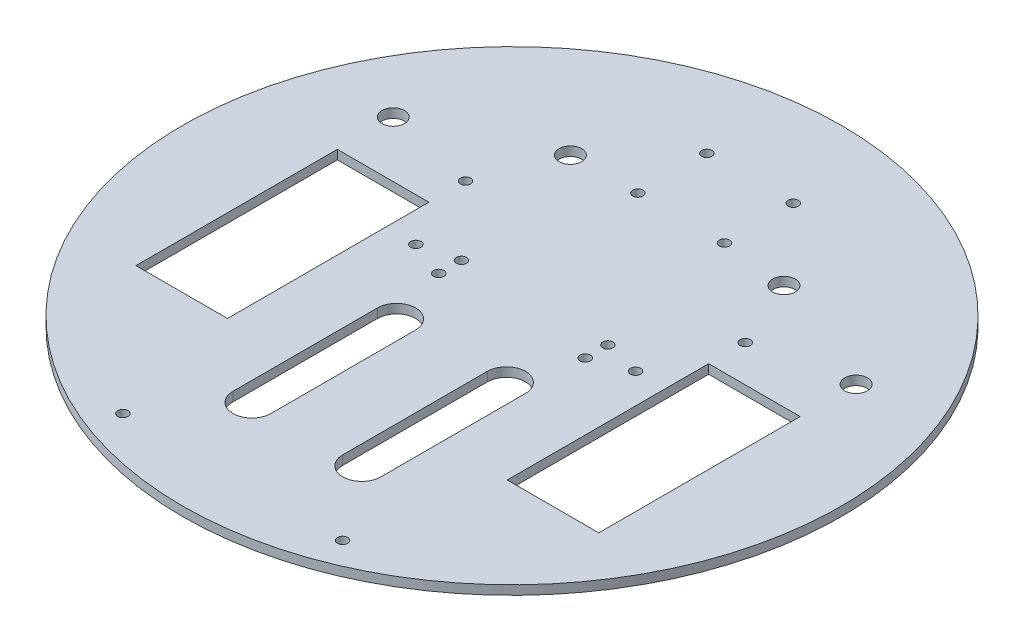
from build123d import *

# Parameters (mm, degrees)
SKETCH1_R           = 114.3
SKETCH1_R_2         = 1.778
SKETCH1_W           = 31.75
SKETCH1_H           = 69.85
BOSS_EXTRUDE1_DEPTH = 3.175
SKETCH2_R           = 1.778
SKETCH2_R_2         = 3.914780109
CUT_EXTRUDE1_DEPTH  = 25.4


with BuildPart() as part:
    # Sketch1 → Boss-Extrude1 (new body)
    with BuildSketch(Plane(origin=(0, 0, 0), x_dir=(1, 0, 0), z_dir=(0, 1, 0))):
        Circle(SKETCH1_R)
        with Locations((-14.986, 82.55)):
            Circle(SKETCH1_R_2, mode=Mode.SUBTRACT)
        with Locations((14.986, 82.55)):
            Circle(SKETCH1_R_2, mode=Mode.SUBTRACT)
        with Locations((-14.986, 58.674)):
            Circle(SKETCH1_R_2, mode=Mode.SUBTRACT)
        with Locations((14.986, 58.674)):
            Circle(SKETCH1_R_2, mode=Mode.SUBTRACT)
        with Locations((25.4, 7.874)):
            Circle(SKETCH1_R_2, mode=Mode.SUBTRACT)
        with Locations((25.4, 0)):
            Circle(SKETCH1_R_2, mode=Mode.SUBTRACT)
        with Locations((-25.4, 7.874)):
            Circle(SKETCH1_R_2, mode=Mode.SUBTRACT)
        with Locations((-25.4, 0)):
            Circle(SKETCH1_R_2, mode=Mode.SUBTRACT)
        with Locations((64.389, -15.24)):
            Rectangle(SKETCH1_W, SKETCH1_H, mode=Mode.SUBTRACT)
        with Locations((-64.389, -15.24)):
            Rectangle(SKETCH1_W, SKETCH1_H, mode=Mode.SUBTRACT)
    extrude(amount=BOSS_EXTRUDE1_DEPTH)

    # Sketch2 → Cut-Extrude1 (cut)
    with BuildSketch(Plane(origin=(0, 3.175, 0), x_dir=(1, 0, 0), z_dir=(0, 1, 0))):
        with Locations((-48.514, 32.385)):
            Circle(SKETCH2_R)
        with Locations((48.514, 32.385)):
            Circle(SKETCH2_R)
        with Locations((38.1, 4.739101121)):
            Circle(SKETCH2_R)
        with Locations((-38.1, 4.739101121)):
            Circle(SKETCH2_R)
        with Locations((-38.1, -96.860898879)):
            Circle(SKETCH2_R)
        with Locations((38.1, -96.860898879)):
            Circle(SKETCH2_R)
        with Locations((-38.1, 58.35227567)):
            Circle(SKETCH2_R_2)
        with Locations((38.1, 56.230319403)):
            Circle(SKETCH2_R_2)
        with Locations((80.264, 39.067487207)):
            Circle(SKETCH2_R_2)
        with Locations((-80.264, 39.067487207)):
            Circle(SKETCH2_R_2)
        with BuildLine():
            Line((-25.674625229, -71.132444692), (-25.674625229, -20.989353066))
            ThreePointArc((-25.674625229, -20.989353066), (-19.05, -14.364727837), (-12.425374771, -20.989353066))
            Line((-12.425374771, -20.989353066), (-12.425374771, -71.132444692))
            ThreePointArc((-12.425374771, -71.132444692), (-19.05, -77.757069921), (-25.674625229, -71.132444692))
        make_face()
        with BuildLine():
            Line((12.425374771, -71.132444692), (12.425374771, -20.989353066))
            ThreePointArc((12.425374771, -20.989353066), (19.05, -14.364727837), (25.674625229, -20.989353066))
            Line((25.674625229, -20.989353066), (25.674625229, -71.132444692))
            ThreePointArc((25.674625229, -71.132444692), (19.05, -77.757069921), (12.425374771, -71.132444692))
        make_face()
    extrude(amount=-CUT_EXTRUDE1_DEPTH, mode=Mode.SUBTRACT)


solid = part.part
